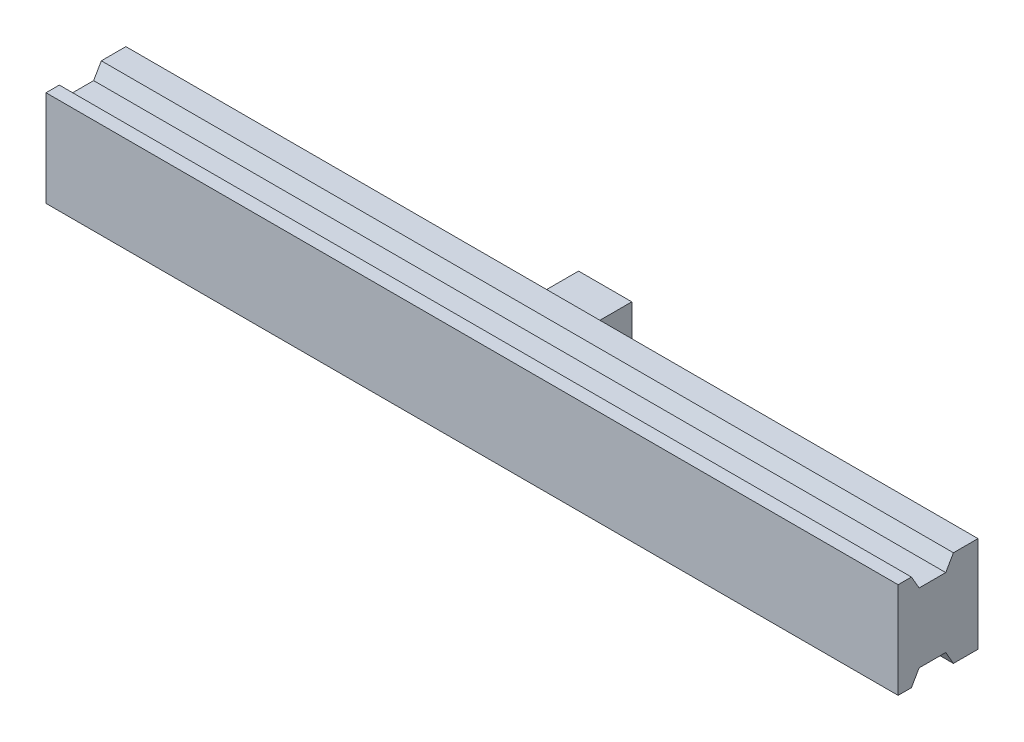
from build123d import *

# Parameters (mm, degrees)
SKETCH1_W           = 160
SKETCH1_H           = 18
BOSS_EXTRUDE1_DEPTH = 15
CUT_EXTRUDE1_DEPTH  = 161
SKETCH3_W           = 10
SKETCH3_H           = 10
BOSS_EXTRUDE2_DEPTH = 10


with BuildPart() as part:
    # Sketch1 → Boss-Extrude1 (new body)
    with BuildSketch(Plane.XY):
        with Locations((415.087037167, 89.382420628)):
            Rectangle(SKETCH1_W, SKETCH1_H)
    extrude(amount=BOSS_EXTRUDE1_DEPTH)

    # Sketch2 → Cut-Extrude1 (cut, through all)
    with BuildSketch(Plane(origin=(495.087037167, 0, 0), x_dir=(0, 0, -1), z_dir=(1, 0, 0))):
        Polygon((-12.5, 98.382420628), (-11.056624327, 95.882420628), (-6.056624327, 95.882420628), (-4.613248654, 98.382420628), align=None)
        Polygon((-4.613248654, 80.382420628), (-12.5, 80.382420628), (-11.056624327, 82.882420628), (-6.056624327, 82.882420628), align=None)
    extrude(amount=-CUT_EXTRUDE1_DEPTH, mode=Mode.SUBTRACT)

    # Sketch3 → Boss-Extrude2 (add)
    with BuildSketch(Plane(origin=(0, 0, 0), x_dir=(-1, 0, 0), z_dir=(0, 0, -1))):
        with Locations((-415.087037167, 89.382420628)):
            Rectangle(SKETCH3_W, SKETCH3_H)
    extrude(amount=BOSS_EXTRUDE2_DEPTH)


solid = part.part
